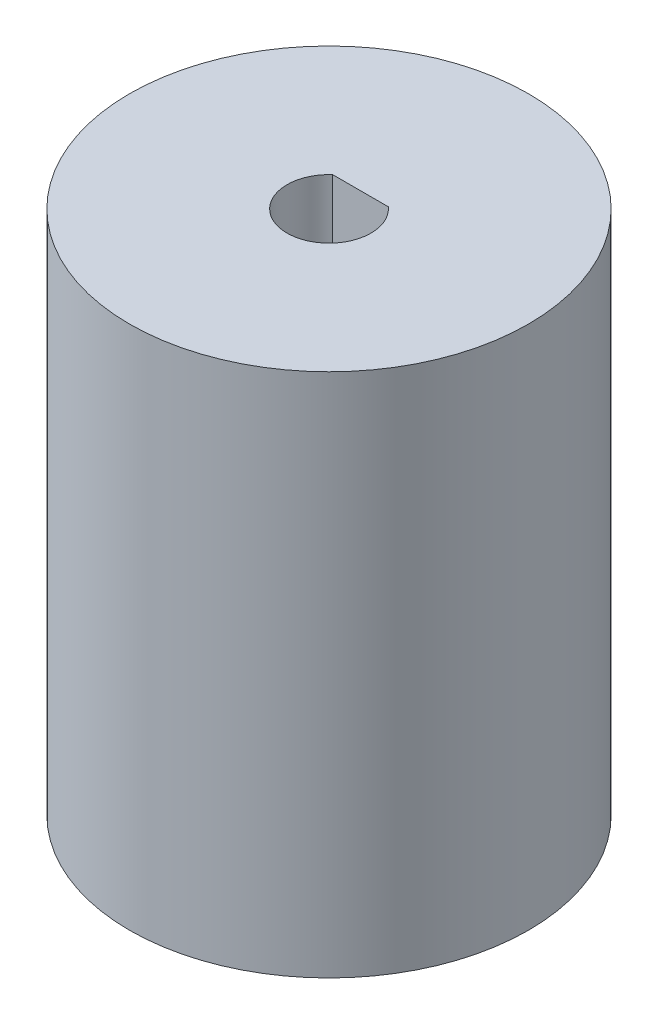
from build123d import *

# Parameters (mm, degrees)
BOSS_EXTRU_1_DEPTH = 7


with BuildPart() as part:
    # Esquisse1 → Révolution1 (revolve)
    with BuildSketch(Plane.XY):
        Polygon((-4, 0), (-4, 18), (-2, 18), (-2, 25), (-9.5, 25), (-9.5, 0), align=None)
    revolve(axis=Axis((0, 0, 0), (0, -1, 0)))

    # Esquisse2 → Boss.-Extru.1 (add)
    with BuildSketch(Plane(origin=(0, 25, 0), x_dir=(1, 0, 0), z_dir=(0, 1, 0))):
        with BuildLine():
            Line((-1.322875656, 1.5), (1.322875656, 1.5))
            ThreePointArc((1.322875656, 1.5), (0, 2), (-1.322875656, 1.5))
        make_face()
    extrude(amount=-BOSS_EXTRU_1_DEPTH)


solid = part.part
